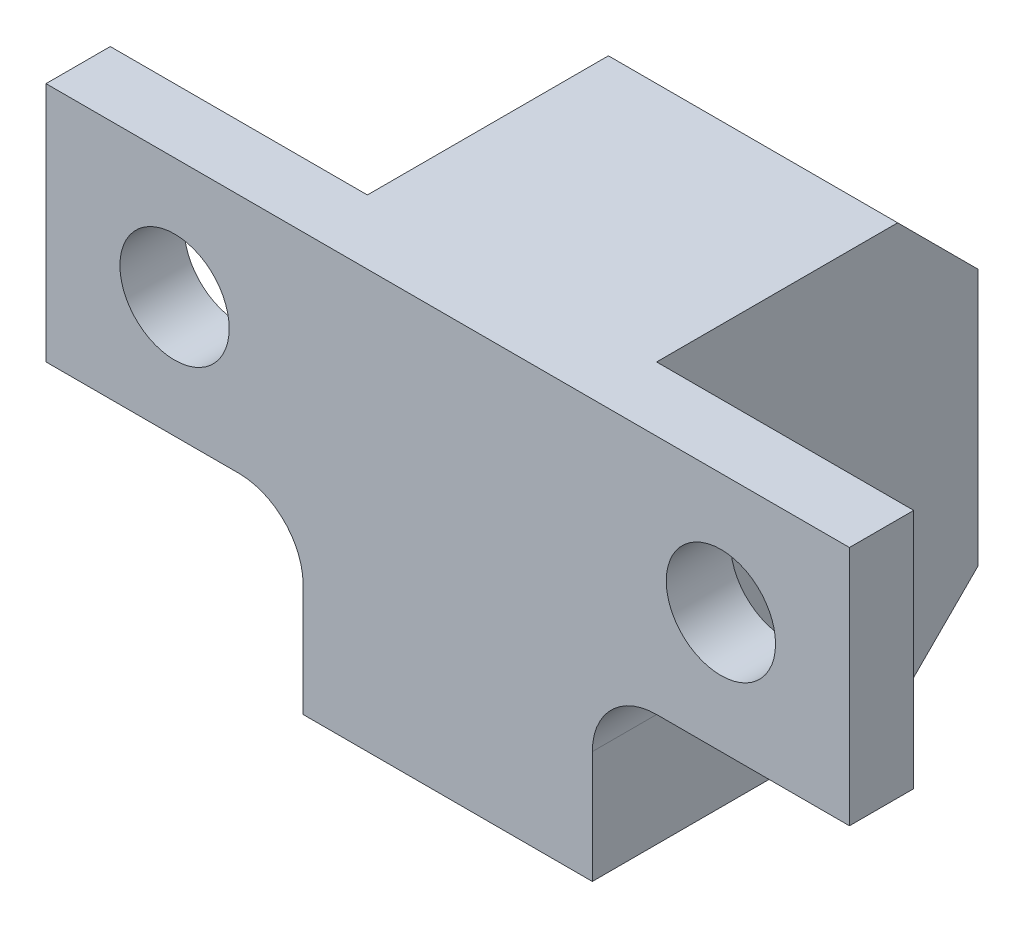
from build123d import *

# Parameters (mm, degrees)
BOSS_EXTRUDE1_DEPTH         = 15
CUT_EXTRUDE2_DEPTH          = 11
CUT_EXTRUDE2_DEPTH_BACK     = 3
M3_CLEARANCE_HOLE1_D        = 3.4
M3_CLEARANCE_HOLE1_DEPTH    = 3.9
M3_CLEARANCE_HOLE1_TIP      = 1.021463052
TAP_DRILL_FOR_M3X0_5_TAP1_D = 2.5
CHAMFER2_SIZE               = 2.5
FILLET1_R                   = 2


with BuildPart() as part:
    # Sketch1 → Boss-Extrude1 (new body)
    with BuildSketch(Plane(origin=(0, 0, 0), x_dir=(1, 0, 0), z_dir=(0, 1, 0))):
        Polygon((0, 0), (8, 0), (8, 10), (17, 10), (17, 0), (25, 0), (25, -2), (0, -2), align=None)
    extrude(amount=BOSS_EXTRUDE1_DEPTH)

    # Sketch5 → Cut-Extrude2 (cut, two sides)
    with BuildSketch(Plane(origin=(0, 0, 0), x_dir=(-1, 0, 0), z_dir=(0, 0, -1))) as cut_extrude2_sk:
        Polygon((-25, 7.5), (-17, 7.5), (-17, 2), (-8, 2), (-8, 7.5), (0, 7.5), (0, 0), (-8, 0), (-17, 0), (-25, 0), align=None)
    extrude(amount=CUT_EXTRUDE2_DEPTH, mode=Mode.SUBTRACT)
    extrude(cut_extrude2_sk.sketch, amount=-CUT_EXTRUDE2_DEPTH_BACK, mode=Mode.SUBTRACT)

    # M3 Clearance Hole1
    with Locations(Plane(origin=(0, 0, 0), x_dir=(-1, 0, 0), z_dir=(0, 0, -1))):
        with Locations((-4, 11.25), (-21, 11.25)):
            Hole(M3_CLEARANCE_HOLE1_D / 2, depth=M3_CLEARANCE_HOLE1_DEPTH)
            with Locations((0, 0, -(M3_CLEARANCE_HOLE1_DEPTH + M3_CLEARANCE_HOLE1_TIP / 2))):  # 118° drill point
                Cone(0, M3_CLEARANCE_HOLE1_D / 2, M3_CLEARANCE_HOLE1_TIP, mode=Mode.SUBTRACT)

    # Tap Drill for M3x0.5 Tap1 (through all)
    with Locations(Plane.ZY.offset(-8)):
        with Locations((-6, 5.25)):
            Hole(TAP_DRILL_FOR_M3X0_5_TAP1_D / 2)

    # Chamfer2
    chamfer2_edges = [part.edges().sort_by_distance(p)[0] for p in [
        (12.5, 15, -10),
        (12.5, 2, -10),
    ]]
    chamfer(chamfer2_edges, length=CHAMFER2_SIZE)

    # Fillet1
    fillet1_edges = [part.edges().sort_by_distance(p)[0] for p in [
        (17, 7.5, 1),
        (8, 7.5, 1),
    ]]
    fillet(fillet1_edges, radius=FILLET1_R)


solid = part.part
